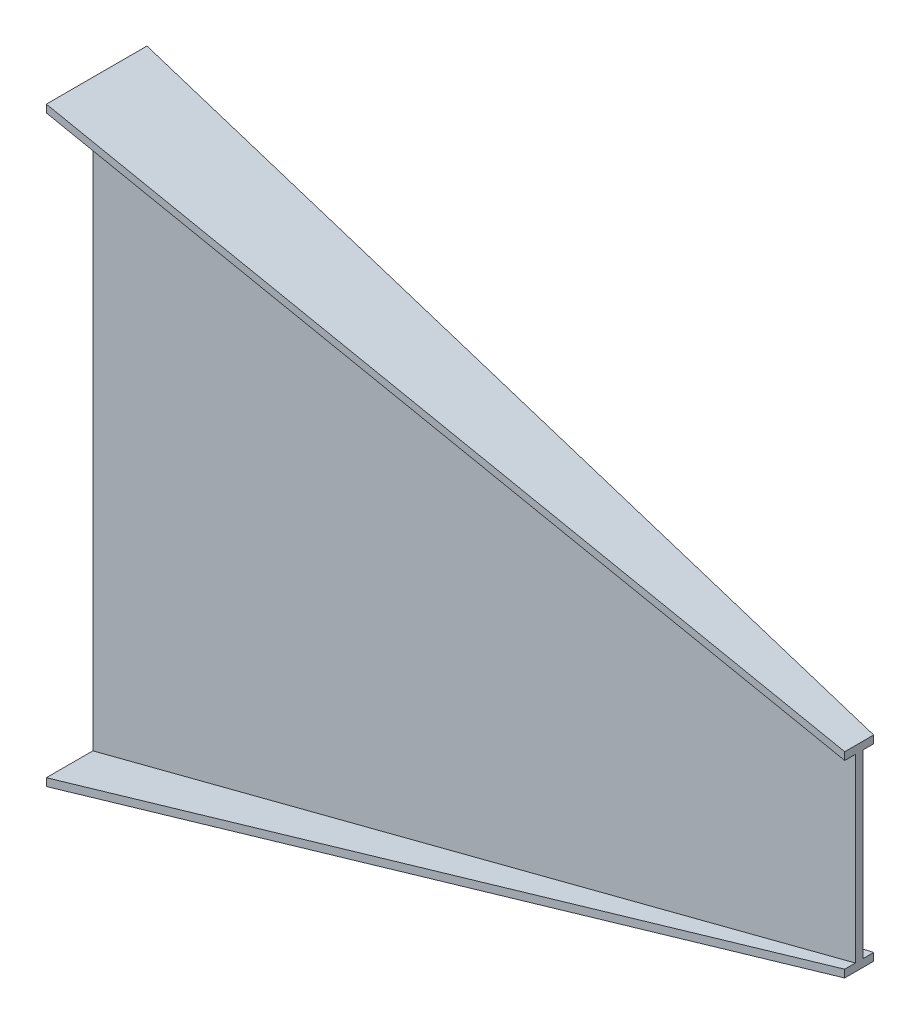
from build123d import *


with BuildPart() as part:
    # Sketch1 → Loft l4 section 0
    with BuildSketch(Plane(origin=(0, 0, 0), x_dir=(0, 0, -1), z_dir=(1, 0, 0))):
        Polygon((-71, 387.5), (61, 387.5), (61, 377.5), (0, 377.5), (0, -377.5), (61, -377.5), (61, -387.5), (-71, -387.5), (-71, -377.5), (-10, -377.5), (-10, 377.5), (-71, 377.5), align=None)
    # Sketch4 → Loft l4 section 1
    with BuildSketch(Plane(origin=(1000, 0, -1000), x_dir=(0, 0, 1), z_dir=(-1, 0, 0))):
        Polygon((986, 128.5), (1024, 128.5), (1024, 118.5), (1010, 118.5), (1010, -118.5), (1024, -118.5), (1024, -128.5), (986, -128.5), (986, -118.5), (1000, -118.5), (1000, 118.5), (986, 118.5), align=None)
    loft()


solid = part.part
